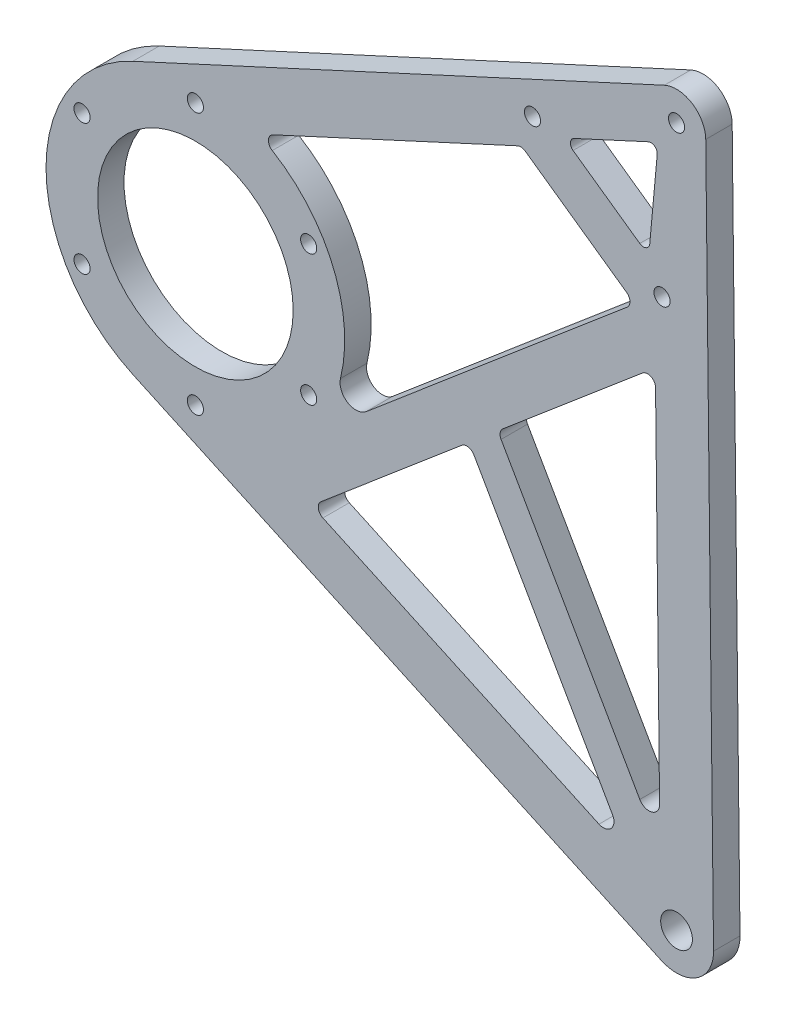
from build123d import *

# Parameters (mm, degrees)
SKETCH_1_R               = 18.5
SKETCH_1_R_2             = 1.525
SKETCH_1_R_3             = 3
EXTRUDE_1_DEPTH          = 2.5
SKETCH_4_R               = 1.525
CUT_EXTRUDE_3_DEPTH      = 10
PATTERN_CIRCULAR_2_COUNT = 6
SKETCH_5_R               = 1.525
CUT_EXTRUDE_4_DEPTH      = 31.54
CUT_EXTRUDE_5_DEPTH      = 31.54
EXTRUDE_2_DEPTH          = 5
EXTRUDE_3_DEPTH          = 5
FILLET_2_R               = 1.5
FILLET_2_2_R             = 3
CUT_EXTRUDE_7_DEPTH      = 5
FILLET_4_R               = 1.2
FILLET_5_R               = 2


with BuildPart() as part:
    # Sketch 1 → Extrude 1 (new body, symmetric)
    with BuildSketch(Plane.XY):
        with BuildLine():
            Line((-102.821191847, -92.640522116), (-2.926441218, -138.613082375))
            ThreePointArc((-2.926441218, -138.613082375), (3.8087152, -138.127288993), (6.999564642, -132.176086843))
            Line((6.999564642, -132.176086843), (5.524656378, 0.061619046))
            ThreePointArc((5.524656378, 0.061619046), (2.952791693, 4.66975869), (-2.312992999, 5.01753808))
            Line((-2.312992999, 5.01753808), (-102.837527006, -41.322427799))
            ThreePointArc((-102.837527006, -41.322427799), (-119.260909787, -66.986705315), (-102.821191847, -92.640522116))
        make_face()
        with Locations((-91.010911218, -66.977713005)):
            Circle(SKETCH_1_R, mode=Mode.SUBTRACT)
        Circle(SKETCH_1_R_2, mode=Mode.SUBTRACT)
        with Locations((0, -132.254156223)):
            Circle(SKETCH_1_R_3, mode=Mode.SUBTRACT)
    extrude(amount=EXTRUDE_1_DEPTH, both=True)

    # Sketch 4 → Cut-Extrude 3 (cut)
    with BuildSketch(Plane.XY.offset(2.5)):
        with Locations((-91.010911218, -42.227713005)):
            Circle(SKETCH_4_R)
    cut_extrude_3 = extrude(amount=-CUT_EXTRUDE_3_DEPTH, mode=Mode.SUBTRACT)

    # Pattern Circular 2: Cut-Extrude 3 ×6 about axis
    pattern_circular_2_axis = Axis((-91.010911218, -66.977713005, 0), (0, 0, 1))
    for i in range(1, PATTERN_CIRCULAR_2_COUNT):
        add(cut_extrude_3.rotate(pattern_circular_2_axis, i * 360 / PATTERN_CIRCULAR_2_COUNT), mode=Mode.SUBTRACT)

    # Sketch 5 → Cut-Extrude 4 (cut)
    with BuildSketch(Plane.XY.offset(2.5)):
        with Locations((-2.745656165, -29.87409199)):
            Circle(SKETCH_5_R)
        with Locations((-27.244550661, -12.559238006)):
            Circle(SKETCH_5_R)
    extrude(amount=-CUT_EXTRUDE_4_DEPTH, mode=Mode.SUBTRACT)

    # Sketch 6 → Cut-Extrude 5 (cut)
    with BuildSketch(Plane.XY.offset(2.5)):
        with BuildLine():
            Line((-79.067859687, -41.376423581), (-29.316651197, -18.44202924))
            Line((-29.316651197, -18.44202924), (-4.070575386, -36.284961557))
            Line((-4.070575386, -36.284961557), (-3.117843226, -121.705267485))
            ThreePointArc((-3.117843226, -121.705267485), (-5.985123886, -123.024947586), (-8.359603594, -125.104538908))
            Line((-8.359603594, -125.104538908), (-79.051563719, -92.57139401))
            ThreePointArc((-79.051563719, -92.57139401), (-62.760912649, -66.968720694), (-79.067859687, -41.376423581))
        make_face()
    extrude(amount=-CUT_EXTRUDE_5_DEPTH, mode=Mode.SUBTRACT)

    # Sketch 7 → Extrude 2 (add)
    with BuildSketch(Plane.XY.offset(2.5)):
        with BuildLine():
            Line((-73.548163223, -95.104113791), (-69.036338231, -97.180500639))
            Line((-69.036338231, -97.180500639), (-4.005429036, -42.12586983))
            Line((-4.005429036, -42.12586983), (-4.070575386, -36.284961557))
            Line((-4.070575386, -36.284961557), (-7.866276061, -33.602309776))
            Line((-7.866276061, -33.602309776), (-72.757541368, -88.538719222))
            ThreePointArc((-72.757541368, -88.538719222), (-75.770580222, -90.764154755), (-79.051563719, -92.57139401))
            Line((-79.051563719, -92.57139401), (-73.548163223, -95.104113791))
        make_face()
    extrude(amount=-EXTRUDE_2_DEPTH)

    # Sketch 8 → Extrude 3 (add)
    with BuildSketch(Plane(origin=(0, 0, -2.5), x_dir=(-1, 0, 0), z_dir=(0, 0, -1))):
        Polygon((7.967241055, -126.608441364), (39.55881203, -71.391285075), (33.804329575, -67.353372997), (1.891384262, -123.132241683), align=None)
    extrude(amount=-EXTRUDE_3_DEPTH)

    # Fillet 2
    fillet_2_edges = [part.edges().sort_by_distance(p)[0] for p in [
        (-69.036338231, -97.180500639, 0),
        (-39.237437692, -71.952997472, 0),
        (-33.804329575, -67.353372997, 0),
        (-4.005429036, -42.12586983, 0),
        (-7.866276061, -33.602309776, 0),
        (-79.067859687, -41.376423581, 0),
        (-29.316651197, -18.44202924, 0),
    ]]
    fillet(fillet_2_edges, radius=FILLET_2_R)

    # Fillet 2 2
    fillet_2_2_edges = [part.edges().sort_by_distance(p)[0] for p in [
        (-72.757541368, -88.538719222, 0),
    ]]
    fillet(fillet_2_2_edges, radius=FILLET_2_2_R)

    # Sketch 12 → Cut-Extrude 7 (cut)
    with BuildSketch(Plane.XY.offset(2.5)):
        Polygon((-3.462970797, -4.899778899), (-21.269732263, -13.108369239), (-5.257503766, -24.425181858), align=None)
    extrude(amount=-CUT_EXTRUDE_7_DEPTH, mode=Mode.SUBTRACT)

    # Fillet 4
    fillet_4_edges = [part.edges().sort_by_distance(p)[0] for p in [
        (-3.462970797, -4.899778899, 0),
        (-5.257503766, -24.425181858, 0),
        (-21.269732263, -13.108369239, 0),
    ]]
    fillet(fillet_4_edges, radius=FILLET_4_R)

    # Fillet 5
    fillet_5_edges = [part.edges().sort_by_distance(p)[0] for p in [
        (-8.994965293, -124.812139119, 0),
        (-3.125995679, -120.974332802, 0),
    ]]
    fillet(fillet_5_edges, radius=FILLET_5_R)


solid = part.part
